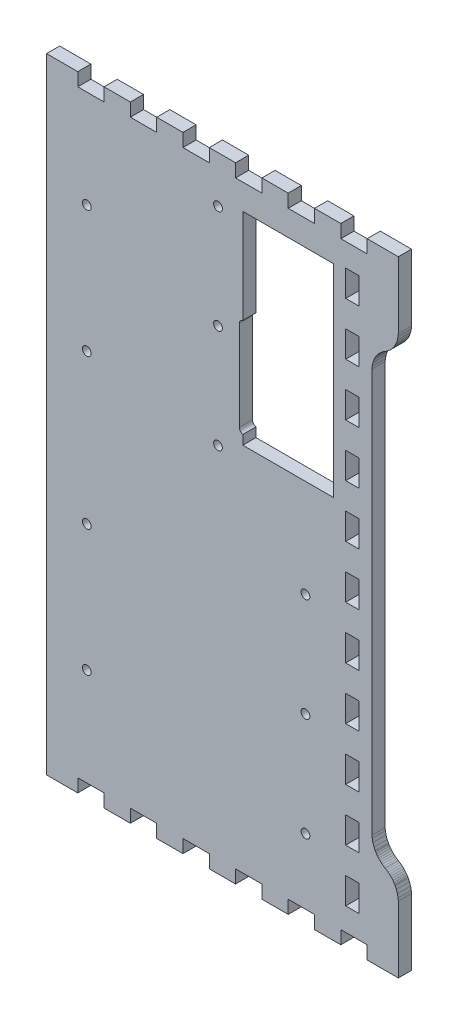
from build123d import *

# Parameters (mm, degrees)
BOSS_EXTRUDE1_DEPTH   = 5.715
CUT_EXTRUDE1_DEPTH    = 6.715
F_6_CLEARANCE_HOLE1_D = 3.7973


with BuildPart() as part:
    # Model → Boss-Extrude1 (new body)
    with BuildSketch(Plane.XY):
        Polygon((1382.75, 22.8575), (1396.32, 22.8575), (1396.32, 28.5722), (1407.75, 28.5722), (1407.75, 22.8575), (1419.18, 22.8575), (1419.18, 28.5722), (1430.61, 28.5722), (1430.61, 22.8575), (1442.04, 22.8575), (1442.04, 28.5722), (1453.47, 28.5722), (1453.47, 22.8575), (1464.9, 22.8575), (1464.9, 28.5722), (1476.33, 28.5722), (1476.33, 22.8575), (1487.76, 22.8575), (1487.76, 28.5722), (1499.19, 28.5722), (1499.19, 22.8575), (1510.62, 22.8575), (1510.62, 28.5722), (1522.05, 28.5722), (1522.05, 22.8575), (1535.61, 22.8575), (1535.61, 28.5722), (1535.61, 51.4325), (1535.61, 51.8072), (1535.51, 52.9276), (1535.22, 54.3913), (1534.74, 55.8038), (1534.27, 56.8247), (1534.08, 57.1472), (1533.99, 57.3098), (1533.68, 57.7854), (1533.25, 58.3928), (1532.77, 58.9703), (1532.27, 59.5147), (1531.72, 60.0244), (1531.14, 60.4986), (1530.53, 60.9353), (1530.06, 61.2387), (1529.9, 61.3311), (1529.74, 61.4246), (1529.26, 61.728), (1528.65, 62.1647), (1528.07, 62.6389), (1527.53, 63.1486), (1527.02, 63.693), (1526.55, 64.2705), (1526.11, 64.878), (1525.81, 65.3535), (1525.71, 65.5147), (1525.53, 65.8386), (1525.05, 66.8595), (1524.57, 68.272), (1524.28, 69.7357), (1524.18, 70.8561), (1524.18, 71.2294), (1524.18, 245.915), (1524.18, 246.29), (1524.28, 247.41), (1524.57, 248.874), (1525.05, 250.286), (1525.53, 251.307), (1525.71, 251.63), (1525.81, 251.792), (1526.11, 252.268), (1526.55, 252.876), (1527.02, 253.453), (1527.53, 253.997), (1528.07, 254.507), (1528.65, 254.981), (1529.26, 255.418), (1529.74, 255.72), (1529.9, 255.814), (1530.06, 255.907), (1530.53, 256.211), (1531.14, 256.647), (1531.72, 257.121), (1532.27, 257.631), (1532.77, 258.175), (1533.25, 258.753), (1533.68, 259.36), (1533.99, 259.836), (1534.08, 259.997), (1534.27, 260.321), (1534.74, 261.342), (1535.22, 262.755), (1535.51, 264.218), (1535.61, 265.339), (1535.61, 265.712), (1535.61, 288.572), (1535.61, 294.287), (1522.05, 294.287), (1522.05, 288.572), (1510.62, 288.572), (1510.62, 294.287), (1499.19, 294.287), (1499.19, 288.572), (1487.76, 288.572), (1487.76, 294.287), (1476.33, 294.287), (1476.33, 288.572), (1464.9, 288.572), (1464.9, 294.287), (1453.47, 294.287), (1453.47, 288.572), (1442.04, 288.572), (1442.04, 294.287), (1430.61, 294.287), (1430.61, 288.572), (1419.18, 288.572), (1419.18, 294.287), (1407.75, 294.287), (1407.75, 288.572), (1396.32, 288.572), (1396.32, 294.287), (1382.75, 294.287), (1382.75, 288.572), (1382.75, 28.5722), align=None)
        Polygon((1518.47, 44.2722), (1518.47, 38.5576), (1512.75, 38.5576), (1512.75, 49.9868), (1518.47, 49.9868), align=None, mode=Mode.SUBTRACT)
        Polygon((1518.47, 67.1326), (1518.47, 61.4179), (1512.75, 61.4179), (1512.75, 72.8472), (1518.47, 72.8472), align=None, mode=Mode.SUBTRACT)
        Polygon((1518.47, 89.9929), (1518.47, 84.2779), (1512.75, 84.2779), (1512.75, 95.7076), (1518.47, 95.7076), align=None, mode=Mode.SUBTRACT)
        Polygon((1518.47, 112.853), (1518.47, 107.137), (1512.75, 107.137), (1512.75, 118.568), (1518.47, 118.568), align=None, mode=Mode.SUBTRACT)
        Polygon((1518.47, 135.712), (1518.47, 129.997), (1512.75, 129.997), (1512.75, 141.428), (1518.47, 141.428), align=None, mode=Mode.SUBTRACT)
        Polygon((1518.47, 158.572), (1518.47, 152.858), (1512.75, 152.858), (1512.75, 164.287), (1518.47, 164.287), align=None, mode=Mode.SUBTRACT)
        Polygon((1518.47, 181.433), (1518.47, 175.718), (1512.75, 175.718), (1512.75, 187.147), (1518.47, 187.147), align=None, mode=Mode.SUBTRACT)
        Polygon((1518.47, 204.293), (1518.47, 198.578), (1512.75, 198.578), (1512.75, 210.008), (1518.47, 210.008), align=None, mode=Mode.SUBTRACT)
        Polygon((1518.47, 227.153), (1518.47, 221.437), (1512.75, 221.437), (1512.75, 232.868), (1518.47, 232.868), align=None, mode=Mode.SUBTRACT)
        Polygon((1518.47, 250.012), (1518.47, 244.297), (1512.75, 244.297), (1512.75, 255.728), (1518.47, 255.728), align=None, mode=Mode.SUBTRACT)
        Polygon((1518.47, 272.872), (1518.47, 267.158), (1512.75, 267.158), (1512.75, 278.587), (1518.47, 278.587), align=None, mode=Mode.SUBTRACT)
    extrude(amount=BOSS_EXTRUDE1_DEPTH)

    # Sketch1 → Cut-Extrude1 (cut, through all)
    with BuildSketch(Plane(origin=(0, 0, 0), x_dir=(-1, 0, 0), z_dir=(0, 0, -1))):
        with BuildLine():
            Line((-1468.0398, 277.5723), (-1507.5398, 277.5723))
            Line((-1507.5398, 277.5723), (-1507.5398, 189.5723))
            Line((-1507.5398, 189.5723), (-1468.0398, 189.5723))
            Line((-1468.0398, 189.5723), (-1468.0398, 193.624933404))
            ThreePointArc((-1468.0398, 193.624933404), (-1466.960094146, 194.312961338), (-1466.5398, 195.5223))
            Line((-1466.5398, 195.5223), (-1466.5398, 234.6223))
            ThreePointArc((-1466.5398, 234.6223), (-1466.960094146, 235.831638662), (-1468.0398, 236.519666596))
            Line((-1468.0398, 236.519666596), (-1468.0398, 277.5723))
        make_face()
    extrude(amount=-CUT_EXTRUDE1_DEPTH, mode=Mode.SUBTRACT)

    # #6 Clearance Hole1 (through all)
    with Locations(Plane(origin=(0, 0, 0), x_dir=(-1, 0, 0), z_dir=(0, 0, -1))):
        with Locations((-1400.25, 246.0721), (-1400.25, 191.0721), (-1400.25, 126.0721), (-1400.25, 71.0721), (-1457.2548, 274.072), (-1457.2548, 229.072), (-1457.2548, 184.072), (-1495.2548, 147.02225), (-1495.2548, 102.02225), (-1495.2548, 57.02225)):
            Hole(F_6_CLEARANCE_HOLE1_D / 2)


solid = part.part
